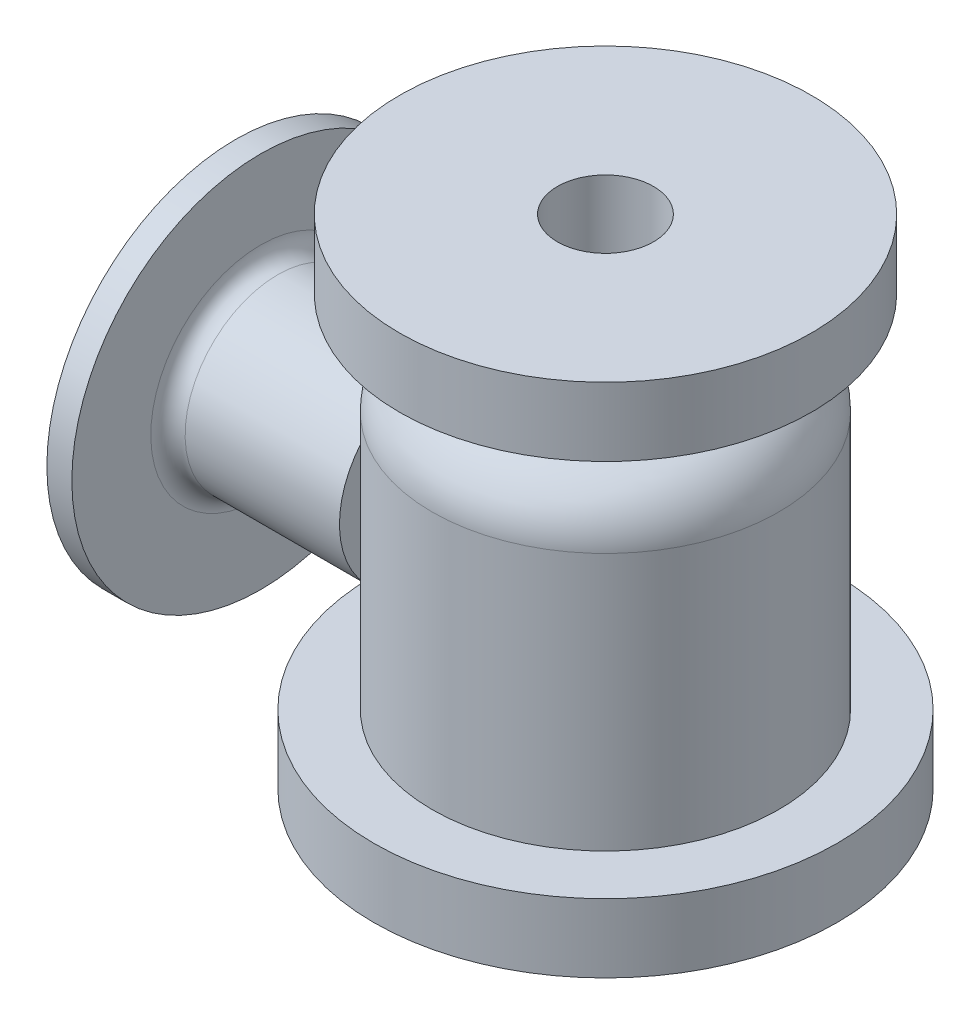
from build123d import *


with BuildPart() as part:
    # Sketch1 → Revolve-Thin2 (revolve)
    with BuildSketch(Plane.XY):
        with BuildLine():
            Line((101, -145), (101, 5.17286724))
            ThreePointArc((101, 5.17286724), (95.571479922, 24.182986003), (80.923076923, 37.459948578))
            ThreePointArc((80.923076923, 37.459948578), (74.41267559, 43.360820833), (72, 51.809762506))
            Line((72, 51.809762506), (72, 65))
            Line((72, 65), (120, 65))
            Line((120, 65), (120, 105))
            Line((120, 105), (28, 105))
            Line((28, 105), (28, 54))
            Line((28, 54), (36, 54))
            Line((36, 54), (36, 7.857864376))
            Line((36, 7.857864376), (43.857864376, 0))
            Line((43.857864376, 0), (47, 0))
            Line((47, 0), (47, -10))
            Line((47, -10), (65, -10))
            Line((65, -10), (65, -176))
            Line((65, -176), (69, -176))
            Line((69, -176), (69, -185))
            Line((69, -185), (135, -185))
            Line((135, -185), (135, -145))
            Line((135, -145), (101, -145))
        make_face()
        with BuildLine():
            Line((91, -145), (91, 5.17286724))
            ThreePointArc((91, 5.17286724), (87.079402166, 18.902397458), (76.5, 28.491314873))
            ThreePointArc((76.5, 28.491314873), (65.920597834, 38.080232288), (62, 51.809762506))
            Line((62, 51.809762506), (62, 65))
            ThreePointArc((62, 65), (64.928932188, 72.071067812), (72, 75))
            Line((72, 75), (110, 75))
            Line((110, 75), (110, 95))
            Line((110, 95), (38, 95))
            Line((38, 95), (38, 64))
            Line((38, 64), (41, 64))
            ThreePointArc((41, 64), (44.535533906, 62.535533906), (46, 59))
            Line((46, 59), (46, 12))
            Line((46, 12), (48, 10))
            Line((48, 10), (57, 10))
            Line((57, 10), (57, 0))
            Line((57, 0), (65, 0))
            ThreePointArc((65, 0), (72.071067812, -2.928932188), (75, -10))
            Line((75, -10), (75, -166))
            Line((75, -166), (79, -166))
            Line((79, -166), (79, -175))
            Line((79, -175), (125, -175))
            Line((125, -175), (125, -155))
            Line((125, -155), (101, -155))
            ThreePointArc((101, -155), (93.928932188, -152.071067812), (91, -145))
        make_face(mode=Mode.SUBTRACT)
    revolve(axis=Axis((0, 130.544189359, 0), (0, -1, 0)))


with BuildPart() as body_2:
    # Sketch5 → Revolve1 (revolve)
    with BuildSketch(Plane.XY):
        with BuildLine():
            Line((-215.491575166, 35), (-215.491575166, -37))
            Line((-215.491575166, -37), (-101, -37))
            Line((-101, -37), (-101, -21))
            Line((-101, -21), (-190.934846325, -21))
            ThreePointArc((-190.934846325, -21), (-198.005914137, -18.071067812), (-200.934846325, -11))
            Line((-200.934846325, -11), (-200.934846325, 35))
            Line((-200.934846325, 35), (-215.491575166, 35))
        make_face()
    revolve(axis=Axis((0, -75, 0), (-1, 0, 0)))


solid = Compound([part.part, body_2.part])
